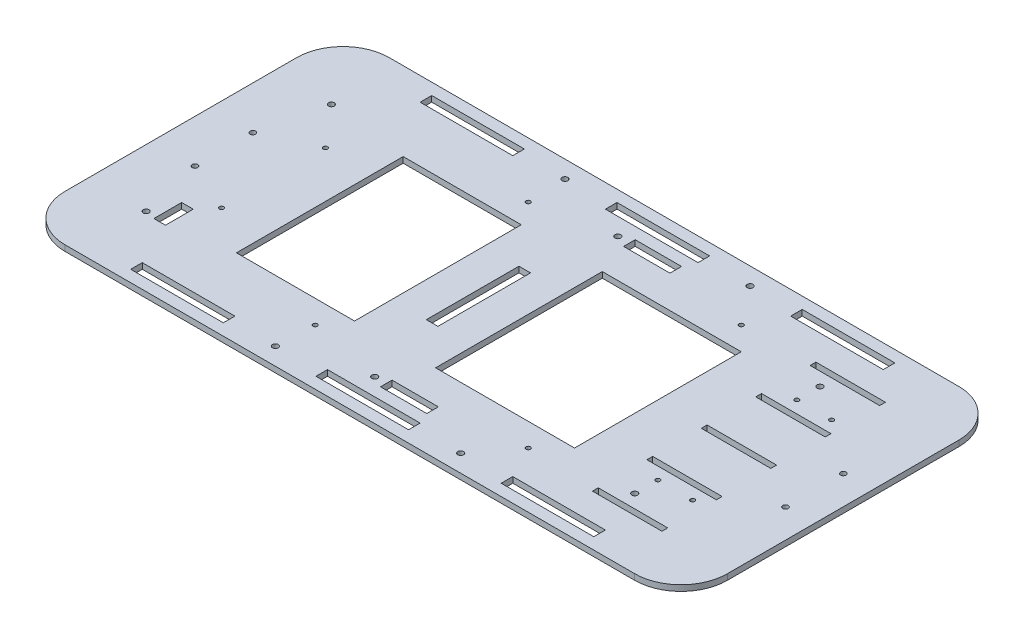
from build123d import *

# Parameters (mm, degrees)
BASEEXTRUDE_DEPTH   = 3.175
SKETCH6_R           = 1.5
MAINMOUNTCUT_DEPTH  = 3.175
SKETCH7_R           = 1.6
SKETCH7_W           = 50.8
SKETCH7_H           = 6.35
WALLCUT_DEPTH       = 4.175
SKETCH8_W           = 38.1
SKETCH8_H           = 3.175
WIREMOUNTCUT_DEPTH  = 4.175
SKETCH9_R           = 1.6
CUT_EXTRUDE3_DEPTH  = 4.175
SKETCH11_W          = 6.35
SKETCH11_H          = 50.8
CUT_EXTRUDE4_DEPTH  = 4.175
SKETCH14_W          = 6.35
SKETCH14_H          = 15.24
CUT_EXTRUDE6_DEPTH  = 4.175
SKETCH15_R          = 1.190625
CUT_EXTRUDE7_DEPTH  = 4.175
SKETCH16_R          = 1.190625
CUT_EXTRUDE8_DEPTH  = 4.175
SKETCH17_W          = 76.2
SKETCH17_H          = 91.44
SKETCH17_W_2        = 64.77
CUT_EXTRUDE9_DEPTH  = 4.175
SKETCH18_R          = 1.6
SKETCH18_W          = 25.4
SKETCH18_H          = 6.35
CUT_EXTRUDE10_DEPTH = 4.175


with BuildPart() as part:
    # Sketch3 → BaseExtrude (new body)
    with BuildSketch(Plane(origin=(0, 0, 0), x_dir=(1, 0, 0), z_dir=(0, 1, 0))):
        with BuildLine():
            Line((-156.21, -88.9), (156.21, -88.9))
            ThreePointArc((156.21, -88.9), (174.170512242, -81.460512242), (181.61, -63.5))
            Line((181.61, -63.5), (181.61, 63.5))
            ThreePointArc((181.61, 63.5), (174.170512242, 81.460512242), (156.21, 88.9))
            Line((156.21, 88.9), (-156.21, 88.9))
            ThreePointArc((-156.21, 88.9), (-174.170512242, 81.460512242), (-181.61, 63.5))
            Line((-181.61, 63.5), (-181.61, -63.5))
            ThreePointArc((-181.61, -63.5), (-174.170512242, -81.460512242), (-156.21, -88.9))
        make_face()
    extrude(amount=-BASEEXTRUDE_DEPTH)

    # Sketch6 → MainMountCut (cut)
    with BuildSketch(Plane(origin=(0, 0, 0), x_dir=(1, 0, 0), z_dir=(0, 1, 0))):
        with Locations((-157.988, 15.875)):
            Circle(SKETCH6_R)
        with Locations((-157.988, -15.875)):
            Circle(SKETCH6_R)
        with Locations((165.862, -15.875)):
            Circle(SKETCH6_R)
        with Locations((165.862, 15.875)):
            Circle(SKETCH6_R)
    extrude(amount=-MAINMOUNTCUT_DEPTH, mode=Mode.SUBTRACT)

    # Sketch7 → WallCut (cut, through all)
    with BuildSketch(Plane(origin=(0, 0, 0), x_dir=(1, 0, 0), z_dir=(0, 1, 0))):
        with Locations((51.223333333, 79.375)):
            Circle(SKETCH7_R)
        with Locations((-50.376666667, 79.375)):
            Circle(SKETCH7_R)
        with Locations((-50.376666667, -79.375)):
            Circle(SKETCH7_R)
        with Locations((51.223333333, -79.375)):
            Circle(SKETCH7_R)
        with Locations((102.023333333, -79.375)):
            Rectangle(SKETCH7_W, SKETCH7_H)
        with Locations((0.423333333, -79.375)):
            Rectangle(SKETCH7_W, SKETCH7_H)
        with Locations((-101.176666667, -79.375)):
            Rectangle(SKETCH7_W, SKETCH7_H)
        with Locations((102.023333333, 79.375)):
            Rectangle(SKETCH7_W, SKETCH7_H)
        with Locations((0.423333333, 79.375)):
            Rectangle(SKETCH7_W, SKETCH7_H)
        with Locations((-101.176666667, 79.375)):
            Rectangle(SKETCH7_W, SKETCH7_H)
    extrude(amount=-WALLCUT_DEPTH, mode=Mode.SUBTRACT)

    # Sketch8 → WireMountCut (cut, through all)
    with BuildSketch(Plane(origin=(0, 0, 0), x_dir=(1, 0, 0), z_dir=(0, 1, 0))):
        with Locations((124.46, -59.69)):
            Rectangle(SKETCH8_W, SKETCH8_H)
        with Locations((124.46, -29.845)):
            Rectangle(SKETCH8_W, SKETCH8_H)
        with Locations((124.46, 0)):
            Rectangle(SKETCH8_W, SKETCH8_H)
        with Locations((124.46, 29.845)):
            Rectangle(SKETCH8_W, SKETCH8_H)
        with Locations((124.46, 59.69)):
            Rectangle(SKETCH8_W, SKETCH8_H)
    extrude(amount=-WIREMOUNTCUT_DEPTH, mode=Mode.SUBTRACT)

    # Sketch9 → Cut-Extrude3 (cut, through all)
    with BuildSketch(Plane(origin=(0, 0, 0), x_dir=(1, 0, 0), z_dir=(0, 1, 0))):
        with Locations((118.11, 50.8)):
            Circle(SKETCH9_R)
        with Locations((118.11, -50.8)):
            Circle(SKETCH9_R)
        with Locations((-149.86, -50.8)):
            Circle(SKETCH9_R)
        with Locations((-149.86, 50.8)):
            Circle(SKETCH9_R)
    extrude(amount=-CUT_EXTRUDE3_DEPTH, mode=Mode.SUBTRACT)

    # Sketch11 → Cut-Extrude4 (cut, through all)
    with BuildSketch(Plane(origin=(0, 0, 0), x_dir=(1, 0, 0), z_dir=(0, 1, 0))):
        with Locations((-18.415, 0)):
            Rectangle(SKETCH11_W, SKETCH11_H)
    extrude(amount=-CUT_EXTRUDE4_DEPTH, mode=Mode.SUBTRACT)

    # Sketch14 → Cut-Extrude6 (cut, through all)
    with BuildSketch(Plane(origin=(0, 0, 0), x_dir=(1, 0, 0), z_dir=(0, 1, 0))):
        with Locations((-141.156855902, -44.45)):
            Rectangle(SKETCH14_W, SKETCH14_H)
    extrude(amount=-CUT_EXTRUDE6_DEPTH, mode=Mode.SUBTRACT)

    # Sketch15 → Cut-Extrude7 (cut, through all)
    with BuildSketch(Plane(origin=(0, 0, 0), x_dir=(1, 0, 0), z_dir=(0, 1, 0))):
        with Locations((67.31, -58.42)):
            Circle(SKETCH15_R)
        with Locations((-49.53, -58.42)):
            Circle(SKETCH15_R)
        with Locations((-49.53, 58.42)):
            Circle(SKETCH15_R)
        with Locations((67.31, 58.42)):
            Circle(SKETCH15_R)
        with Locations((137.16, -38.1)):
            Circle(SKETCH15_R)
        with Locations((118.11, -38.1)):
            Circle(SKETCH15_R)
        with Locations((137.16, 38.1)):
            Circle(SKETCH15_R)
        with Locations((118.11, 38.1)):
            Circle(SKETCH15_R)
    extrude(amount=-CUT_EXTRUDE7_DEPTH, mode=Mode.SUBTRACT)

    # Sketch16 → Cut-Extrude8 (cut, through all)
    with BuildSketch(Plane(origin=(0, 0, 0), x_dir=(1, 0, 0), z_dir=(0, 1, 0))):
        with Locations((-130.81, -28.5)):
            Circle(SKETCH16_R)
        with Locations((-130.81, 28.5)):
            Circle(SKETCH16_R)
    extrude(amount=-CUT_EXTRUDE8_DEPTH, mode=Mode.SUBTRACT)

    # Sketch17 → Cut-Extrude9 (cut, through all)
    with BuildSketch(Plane(origin=(0, 0, 0), x_dir=(1, 0, 0), z_dir=(0, 1, 0))):
        with Locations((41.91, 0)):
            Rectangle(SKETCH17_W, SKETCH17_H)
        with Locations((-73.025, 0)):
            Rectangle(SKETCH17_W_2, SKETCH17_H)
    extrude(amount=-CUT_EXTRUDE9_DEPTH, mode=Mode.SUBTRACT)

    # Sketch18 → Cut-Extrude10 (cut, through all)
    with BuildSketch(Plane(origin=(0, 0, 0), x_dir=(1, 0, 0), z_dir=(0, 1, 0))):
        with Locations((-8.636, -66.675)):
            Circle(SKETCH18_R)
        with Locations((-8.636, 66.675)):
            Circle(SKETCH18_R)
        with Locations((10.414, -66.675)):
            Rectangle(SKETCH18_W, SKETCH18_H)
        with Locations((10.414, 66.675)):
            Rectangle(SKETCH18_W, SKETCH18_H)
    extrude(amount=-CUT_EXTRUDE10_DEPTH, mode=Mode.SUBTRACT)


solid = part.part
